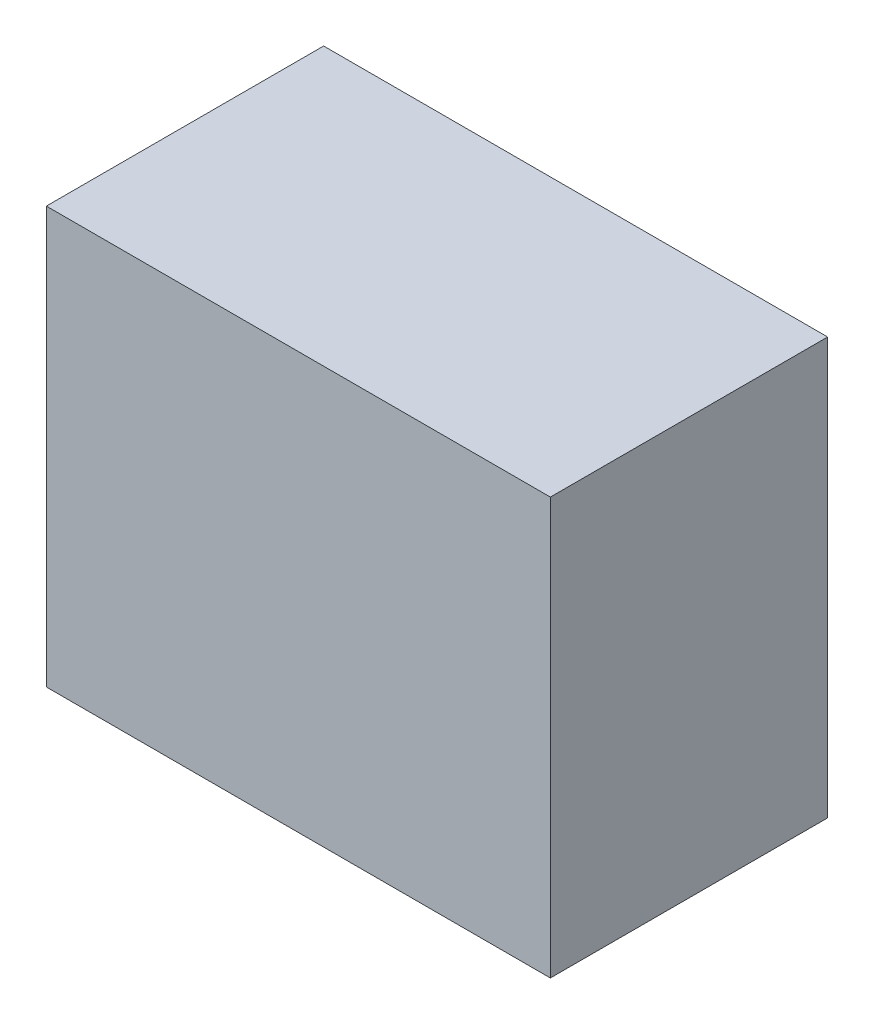
from build123d import *

# Parameters (mm, degrees)
SKETCH2_W           = 329.184
SKETCH2_H           = 272.034
BOSS_EXTRUDE1_DEPTH = 181.102


with BuildPart() as part:
    # Sketch2 → Boss-Extrude1 (new body)
    with BuildSketch(Plane.XY):
        Rectangle(SKETCH2_W, SKETCH2_H)
    extrude(amount=BOSS_EXTRUDE1_DEPTH)


solid = part.part
